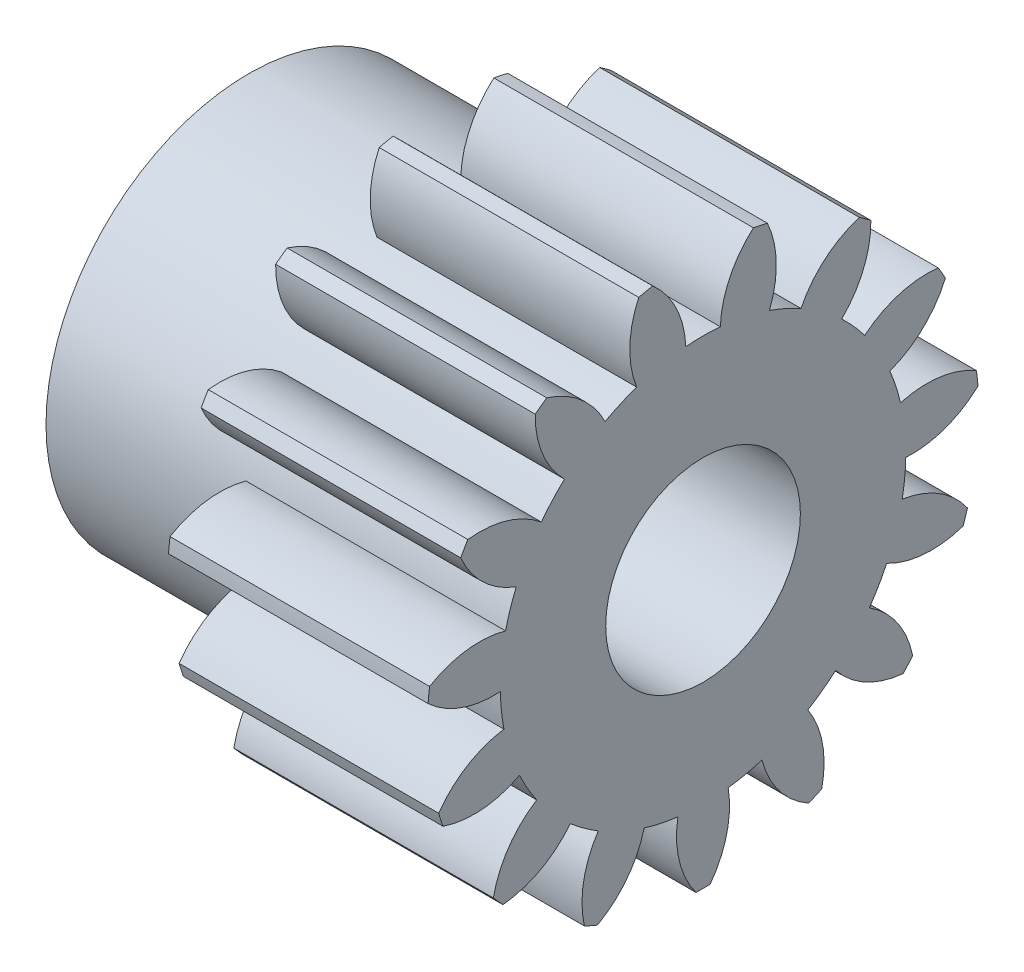
from build123d import *
from build123d.topology import SkipClean

# Parameters (mm, degrees)
BASPROSKE_W      = 8
BASPROSKE_H      = 8.5
TOOTHCUT_DEPTH   = 15.439529078
TEETHCUTS_COUNT  = 15
TEETHCUTS_ANGLE  = 336
HUBNEAONESKE_R   = 6.249
HUBNEARONE_DEPTH = 3.0001524
BORSKE_R         = 3
BORE_DEPTH       = 11.0001524
MOVE_FACE1_BY    = 3


with BuildPart() as part:
    # BasProSke → Base-Revolve (revolve)
    with BuildSketch(Plane(origin=(0, 0, 0), x_dir=(1, 0, 0), z_dir=(0, 1, 0)), mode=Mode.PRIVATE) as base_revolve_sk:
        with Locations((4, 4.25)):
            Rectangle(BASPROSKE_W, BASPROSKE_H)
    revolve(base_revolve_sk.sketch.rotate(Axis((-10, 0, 0), (1, 0, 0)), 180), axis=Axis((-10, 0, 0), (1, 0, 0)))

    # TooCutSke → ToothCut (cut, through all)
    with BuildSketch(Plane(origin=(0, 0, 0), x_dir=(0, 0, -1), z_dir=(1, 0, 0))):
        with BuildLine():
            ThreePointArc((0.531576138, 6.226349477), (0, 6.249), (-0.531576138, 6.226349477))
            ThreePointArc((-0.531576138, 6.226349477), (-0.830301624, 7.411024729), (-1.576608494, 8.378350125))
            ThreePointArc((-1.576608494, 8.378350125), (0, 8.5254), (1.576608494, 8.378350125))
            ThreePointArc((1.576608494, 8.378350125), (0.830301624, 7.411024729), (0.531576138, 6.226349477))
        make_face()
    toothcut = extrude(amount=TOOTHCUT_DEPTH, mode=Mode.SUBTRACT)

    # TeethCuts: ToothCut ×15 about axis
    teethcuts_axis = Axis((-10, 0, 0), (1, 0, 0))
    for i in range(1, TEETHCUTS_COUNT):
        add(toothcut.rotate(teethcuts_axis, i * TEETHCUTS_ANGLE / (TEETHCUTS_COUNT - 1)), mode=Mode.SUBTRACT)

    # HubNeaOneSke → HubNearOne (add)
    with SkipClean():  # the faces are left unmerged after this step: merging them gives an invalid solid
        with BuildSketch(Plane.ZY):
            Circle(HUBNEAONESKE_R)
        extrude(amount=HUBNEARONE_DEPTH)

    # BorSke → Bore (cut, symmetric)
    with SkipClean():  # the faces are left unmerged after this step: merging them gives an invalid solid
        with BuildSketch(Plane(origin=(0, 0, 0), x_dir=(0, 0, -1), z_dir=(1, 0, 0))):
            with Locations(Location((0, 0, 0), (0, 0, 180))):
                Circle(BORSKE_R)
        extrude(amount=BORE_DEPTH, both=True, mode=Mode.SUBTRACT)

    # Move Face1: a face moved outward by 3.0
    extrude(part.faces().sort_by_distance((-3.0001524, -3.1245, 0))[0], amount=MOVE_FACE1_BY, dir=(-1, 0, 0))


solid = part.part
